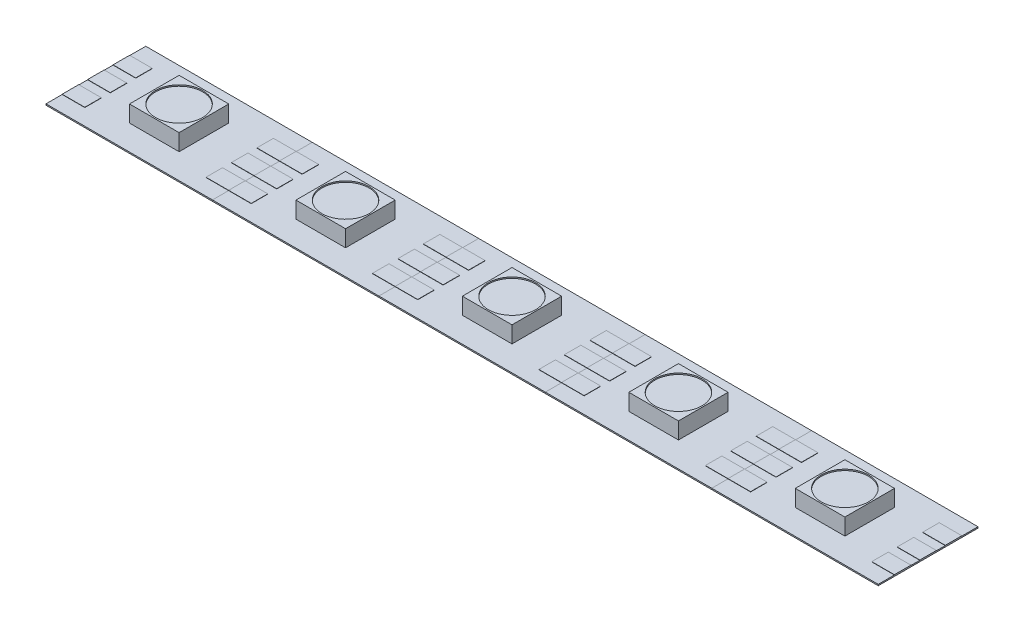
from build123d import *

# Parameters (mm, degrees)
SKETCH1_W           = 16.6116
SKETCH1_H           = 9.9568
BOSS_EXTRUDE1_DEPTH = 0.127
SKETCH3_W           = 4.953
SKETCH3_H           = 4.953
BOSS_EXTRUDE3_DEPTH = 1.651
SKETCH4_W           = 2.258810151
SKETCH4_H           = 1.651
BOSS_EXTRUDE4_DEPTH = 0.0254
SKETCH5_R           = 2.348345572
CUT_EXTRUDE1_DEPTH  = 0.127
LPATTERN1_COUNT     = 5
LPATTERN1_PITCH     = 16.6116


with BuildPart() as part:
    # Sketch1 → Boss-Extrude1 (new body)
    with BuildSketch(Plane(origin=(0, 0, 0), x_dir=(1, 0, 0), z_dir=(0, 1, 0))):
        Rectangle(SKETCH1_W, SKETCH1_H)
    extrude(amount=BOSS_EXTRUDE1_DEPTH)

    # Sketch3 → Boss-Extrude3 (add)
    with BuildSketch(Plane(origin=(0, 0.127, 0), x_dir=(1, 0, 0), z_dir=(0, 1, 0))):
        Rectangle(SKETCH3_W, SKETCH3_H)
    extrude(amount=BOSS_EXTRUDE3_DEPTH)

    # Sketch4 → Boss-Extrude4 (add)
    with BuildSketch(Plane(origin=(0, 0.127, 0), x_dir=(1, 0, 0), z_dir=(0, 1, 0))):
        with Locations((-7.176394925, 0)):
            Rectangle(SKETCH4_W, SKETCH4_H)
        with Locations((-7.176394925, 2.54)):
            Rectangle(SKETCH4_W, SKETCH4_H)
        with Locations((-7.176394925, -2.54)):
            Rectangle(SKETCH4_W, SKETCH4_H)
        with Locations((7.176394925, -2.54)):
            Rectangle(SKETCH4_W, SKETCH4_H)
        with Locations((7.176394925, 0)):
            Rectangle(SKETCH4_W, SKETCH4_H)
        with Locations((7.176394925, 2.54)):
            Rectangle(SKETCH4_W, SKETCH4_H)
    extrude(amount=BOSS_EXTRUDE4_DEPTH)

    # Sketch5 → Cut-Extrude1 (cut)
    with BuildSketch(Plane(origin=(0, 1.778, 0), x_dir=(1, 0, 0), z_dir=(0, 1, 0))):
        Circle(SKETCH5_R)
    extrude(amount=-CUT_EXTRUDE1_DEPTH, mode=Mode.SUBTRACT)


with BuildPart() as lpattern1_1:
    # LPattern1: pattern copy
    add(part.part.moved(Location(Vector(1, 0, 0) * (1 * LPATTERN1_PITCH))))


with BuildPart() as lpattern1_2:
    # LPattern1: pattern copy
    add(part.part.moved(Location(Vector(1, 0, 0) * (2 * LPATTERN1_PITCH))))


with BuildPart() as lpattern1_3:
    # LPattern1: pattern copy
    add(part.part.moved(Location(Vector(1, 0, 0) * (3 * LPATTERN1_PITCH))))


with BuildPart() as lpattern1_4:
    # LPattern1: pattern copy
    add(part.part.moved(Location(Vector(1, 0, 0) * (4 * LPATTERN1_PITCH))))


solid = Compound([part.part, lpattern1_1.part, lpattern1_2.part, lpattern1_3.part, lpattern1_4.part])
